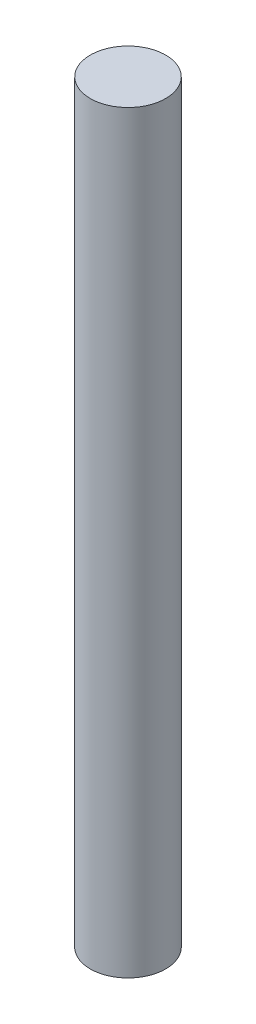
from build123d import *

# Parameters (mm, degrees)
SKETCH1_R           = 2.286
BOSS_EXTRUDE1_DEPTH = 45.72


with BuildPart() as part:
    # Sketch1 → Boss-Extrude1 (new body)
    with BuildSketch(Plane(origin=(0, 0, 0), x_dir=(1, 0, 0), z_dir=(0, 1, 0))):
        Circle(SKETCH1_R)
    extrude(amount=BOSS_EXTRUDE1_DEPTH)


solid = part.part
